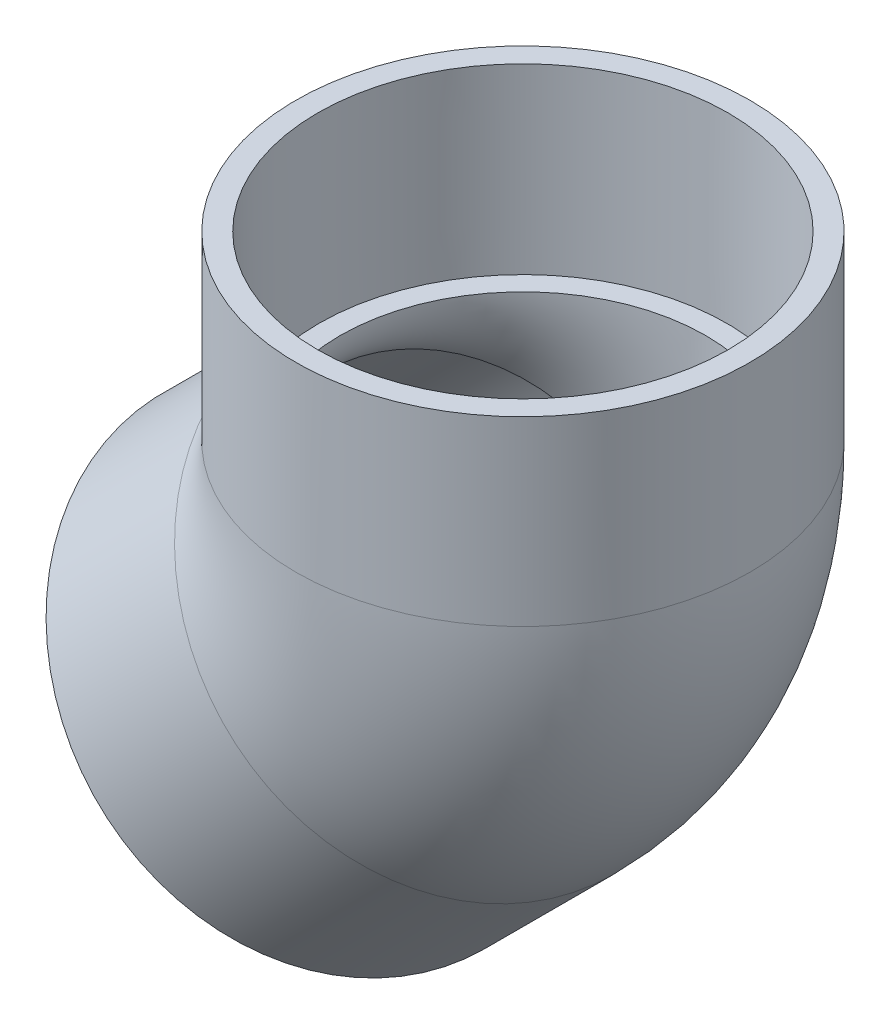
from build123d import *

# Parameters (mm, degrees)
SKETCH3_R   = 63.5
SKETCH3_R_2 = 51.1302


with BuildPart() as part:
    # Sketch1 → Revolve1 (revolve)
    with BuildSketch(Plane.XY):
        Polygon((-10.664054144, -100.466615354), (25.256970341, -64.54559087), (20.686019975, -59.974640505), (-14.992537594, -96.138131904), align=None)
    revolve(axis=Axis((-55.565334749, -55.565334749, 0), (0.7071067811865487, 0.7071067811865465, 0)))



with BuildPart() as body_2:
    # Sketch2 → Revolve2 (revolve)
    with BuildSketch(Plane.XY):
        Polygon((57.3786, 78.58125), (57.0357, 27.78125), (63.5, 27.78125), (63.5, 78.58125), align=None)
    revolve(axis=Axis((0, 0, 0), (0, 1, 0)))


with BuildPart() as part_1:
    add(part.part)

    add(body_2.part)  # Sweep1 merges body 2
    # Sweep1: sweep along a path in Sketch4
    with BuildLine(Plane.XY) as sweep1_path:
        ThreePointArc((-19.644310265, -19.644310265), (-5.105389899, 2.114721737), (0, 27.78125))
    # Sketch3 → Sweep1 (sweep)
    with BuildSketch(Plane(origin=(-19.644310265, -19.644310265, 0), x_dir=(0, 0, -1), z_dir=(0.7071067811865488, 0.7071067811865464, 0))):
        Circle(SKETCH3_R)
        Circle(SKETCH3_R_2, mode=Mode.SUBTRACT)
    sweep(path=sweep1_path.line)


solid = part_1.part
